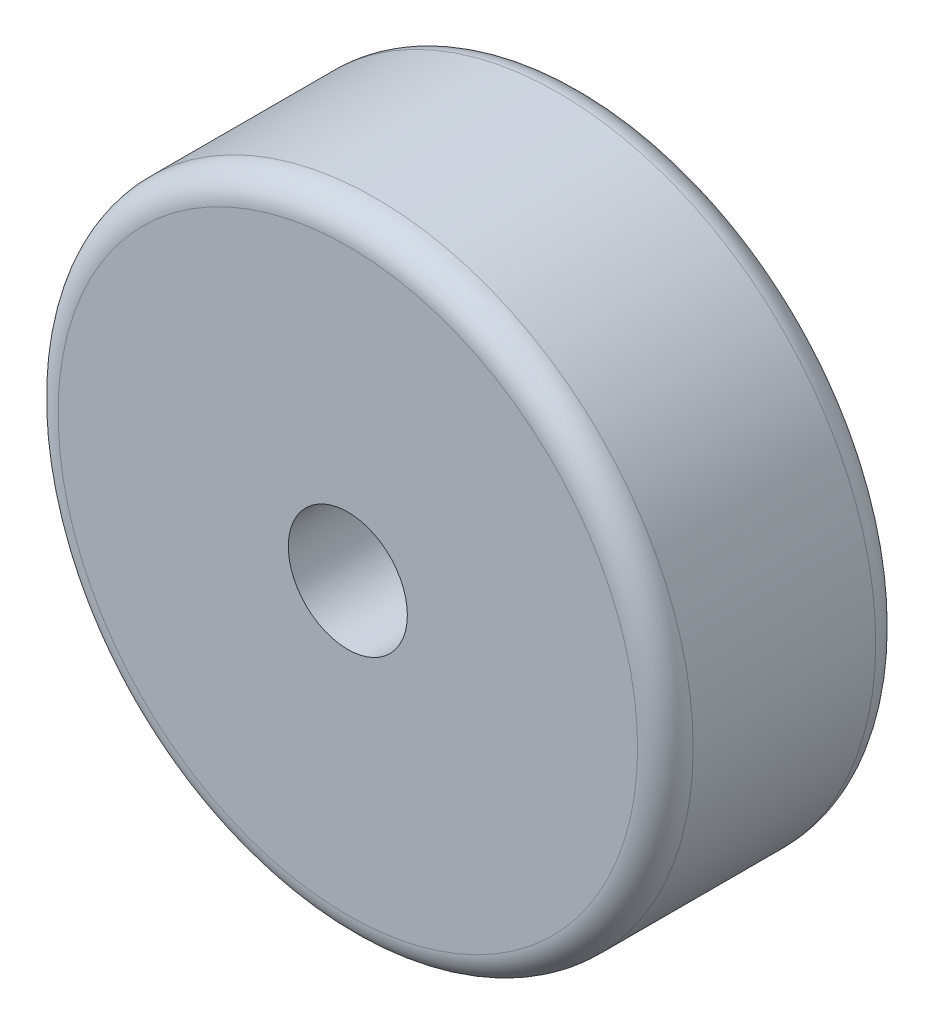
from build123d import *

# Parameters (mm, degrees)
SKETCH1_R           = 101.6
SKETCH1_R_2         = 19.05
BOSS_EXTRUDE1_DEPTH = 38.1
FILLET1_R           = 8.89


with BuildPart() as part:
    # Sketch1 → Boss-Extrude1 (new body, symmetric)
    with BuildSketch(Plane.XY):
        Circle(SKETCH1_R)
        Circle(SKETCH1_R_2, mode=Mode.SUBTRACT)
    extrude(amount=BOSS_EXTRUDE1_DEPTH, both=True)

    # Fillet1
    fillet1_edges = [part.edges().sort_by_distance(p)[0] for p in [
        (-101.6, 0, -38.1),
        (-101.6, 0, 38.1),
    ]]
    fillet(fillet1_edges, radius=FILLET1_R)


solid = part.part
